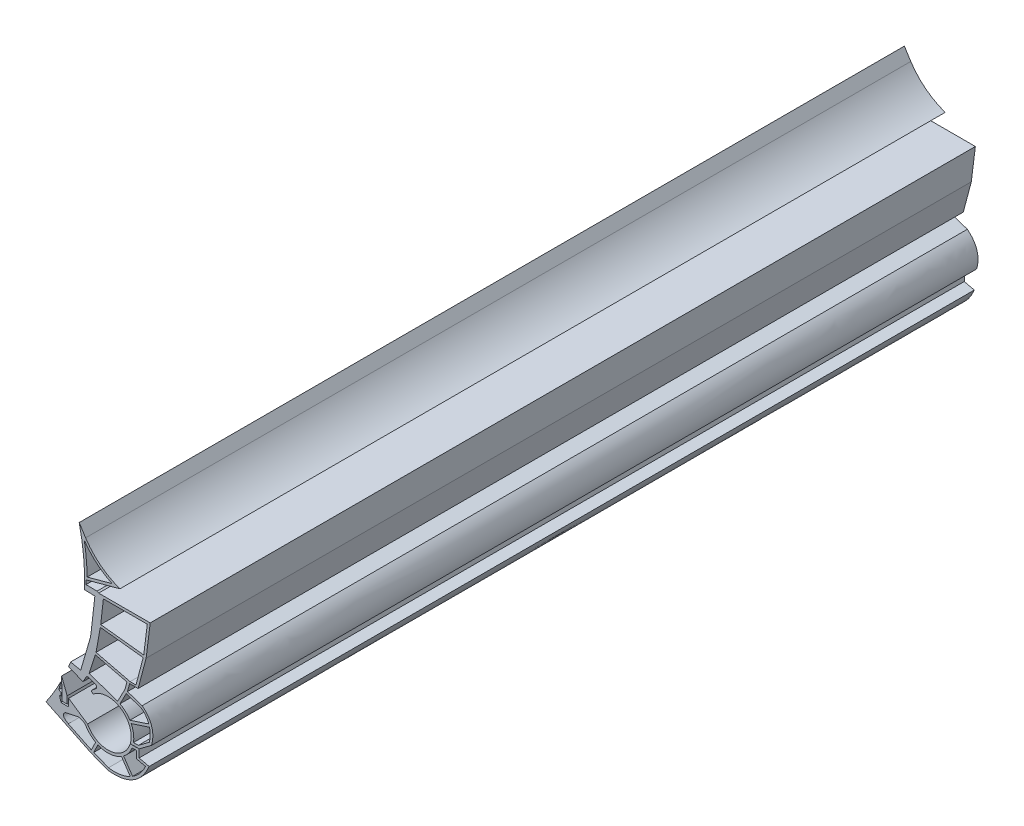
from build123d import *

# Parameters (mm, degrees)
BOSS_EXTRUDE1_DEPTH   = 800
BOSS_EXTRUDE1_2_DEPTH = 800
BOSS_EXTRUDE1_3_DEPTH = 800


with BuildPart() as part:
    # Sketch2 → Boss-Extrude1 (new body)
    with BuildSketch(Plane.XY):
        with BuildLine():
            Line((219.877743808, -7.333333333), (209.883300908, -7))
            ThreePointArc((209.883300908, -7), (209.036823939, 20.089953644), (204.708380722, 46.845265098))
            Line((204.708380722, 46.845265098), (210.908263166, 37.044972147))
            ThreePointArc((210.908263166, 37.044972147), (225.418988897, 21.257964998), (244.224799112, 10.95591384))
            Line((244.224799112, 10.95591384), (211.269993414, 2))
            Line((211.269993414, 2), (211.269993414, -2.012186433))
            Line((211.269993414, -2.012186433), (221.990475975, -2.114290898))
            Line((221.990475975, -2.114290898), (223.530977705, -3.027795155))
            Line((223.530977705, -3.027795155), (273.530977705, -3.027795155))
            Line((273.530977705, -3.027795155), (269.584815864, -34.639562765))
            Line((269.584815864, -34.639562765), (261.828573121, -63.977474169))
            Line((261.828573121, -63.977474169), (253.570603739, -63.920369552))
            Line((253.570603739, -63.920369552), (251.502867564, -71.746815931))
            Line((251.502867564, -71.746815931), (265.756145816, -76.42057877))
            add(Edge.make_bspline(
                [(265.756145816, -76.42057877), (279.732844517, -87.718519491), (274.80699177, -105.243303822)],
                knots=[0, 0, 0, 1, 1, 1], degree=2))
            Line((274.80699177, -105.243303822), (262.889701897, -114.073205773))
            Line((262.889701897, -114.073205773), (254.187014796, -114.073467609))
            ThreePointArc((254.187014796, -114.073467609), (245.005362752, -89.033401072), (218.370489992, -90.408617244))
            Line((218.370489992, -90.408617244), (216.987423166, -89.47817055))
            ThreePointArc((216.987423166, -89.47817055), (216.546928458, -88.6998252), (216.905234712, -87.880390212))
            Line((216.905234712, -87.880390212), (220.932114628, -84.522977972))
            ThreePointArc((220.932114628, -84.522977972), (221.623404057, -82.653573805), (220.356188922, -81.115159421))
            Line((220.356188922, -81.115159421), (213.922645584, -78.692485674))
            ThreePointArc((213.922645584, -78.692485674), (212.546582543, -78.680182493), (211.48830239, -79.559809676))
            Line((211.48830239, -79.559809676), (208.320966691, -85.013968481))
            Line((208.320966691, -85.013968481), (194.432902245, -79.346370583))
            ThreePointArc((194.432902245, -79.346370583), (195.418239612, -76.887655881), (196.372486568, -74.416708601))
            Line((196.372486568, -74.416708601), (206.163211734, -76.451825484))
            Line((206.163211734, -76.451825484), (215.396541258, -44.769744406))
            Line((215.396541258, -44.769744406), (216.201262108, -40.024272027))
            Line((216.201262108, -40.024272027), (219.877743808, -7.333333333))
        make_face()
        Polygon((270.699494071, -5.527795155), (267.255142009, -33.119683511), (225.555597681, -28.430077836), (228.131229539, -5.527795155), align=None, mode=Mode.SUBTRACT)
        Polygon((221.028914069, -54.008130098), (254.057209492, -62.078551489), (259.744710015, -62.078551489), (266.75063601, -35.578705754), (225.193651001, -30.905132557), align=None, mode=Mode.SUBTRACT)
        with BuildLine():
            Line((250.326268176, -73.991973356), (244.224799112, -85.63464351))
            ThreePointArc((244.224799112, -85.63464351), (249.640856314, -89.46696755), (253.858108107, -94.588995513))
            Line((253.858108107, -94.588995513), (272.107313629, -88.577563806))
            ThreePointArc((272.107313629, -88.577563806), (269.17492176, -82.962253968), (264.533682358, -78.650697003))
            Line((264.533682358, -78.650697003), (250.326268176, -73.991973356))
        make_face(mode=Mode.SUBTRACT)
        with BuildLine():
            Line((262.06445628, -111.573205773), (272.619054804, -103.75296551))
            ThreePointArc((272.619054804, -103.75296551), (273.555215096, -97.369625677), (272.889612093, -90.952430327))
            Line((272.889612093, -90.952430327), (255.088866515, -96.816322326))
            ThreePointArc((255.088866515, -96.816322326), (257.336724857, -104.023661365), (257.33049641, -111.573400722))
            Line((257.33049641, -111.573400722), (262.06445628, -111.573205773))
        make_face(mode=Mode.SUBTRACT)
        with BuildLine():
            Line((212.443278327, 4.909530906), (236.506394493, 11.449007942))
            ThreePointArc((236.506394493, 11.449007942), (221.606630296, 21.147833274), (209.704620684, 34.354360188))
            ThreePointArc((209.704620684, 34.354360188), (211.586770977, 19.679642969), (212.443278327, 4.909530906))
        make_face(mode=Mode.SUBTRACT)
        Polygon((249.157757395, -70.835874948), (241.952280674, -84.585184811), (214.328828436, -75.073832175), (220.269405707, -56.396096127), (250.989539733, -63.902521257), align=None, mode=Mode.SUBTRACT)
    extrude(amount=BOSS_EXTRUDE1_DEPTH)


with BuildPart() as body_2:
    # Sketch2 → Boss-Extrude1 2 (new body)
    with BuildSketch(Plane.XY):
        with BuildLine():
            Line((216.469459271, -141.037184205), (172.512257161, -119.747739558))
            ThreePointArc((172.512257161, -119.747739558), (180.123356683, -107.960994704), (186.930410904, -95.692327171))
            Line((186.930410904, -95.692327171), (184.936120706, -103.441553939))
            Line((184.936120706, -103.441553939), (187.292803793, -104.504288635))
            Line((187.292803793, -104.504288635), (187.292803793, -107.504288635))
            Line((187.292803793, -107.504288635), (185.612345377, -108.013264922))
            Line((185.612345377, -108.013264922), (187.166078479, -113.14313822))
            Line((187.166078479, -113.14313822), (194.485119153, -113.14313822))
            Line((194.485119153, -113.14313822), (194.485119153, -105.831804929))
            Line((194.485119153, -105.831804929), (212.772463132, -118.30531603))
            ThreePointArc((212.772463132, -118.30531603), (234.800277303, -130.138906076), (254.127625184, -114.273469605))
            Line((254.127625184, -114.273469605), (262.754736754, -114.273469605))
            Line((262.754736754, -114.273469605), (262.754736754, -121.826061943))
            Line((262.754736754, -121.826061943), (272.500467307, -124.066761831))
            add(Edge.make_bspline(
                [(272.500467307, -124.066761831), (261.187460089, -150.606305517), (232.597385362, -147.208325233)],
                knots=[0, 0, 0, 1, 1, 1], degree=2))
            Line((232.597385362, -147.208325233), (216.469459271, -141.037184205))
        make_face()
        with BuildLine():
            Line((256.441296727, -140.398444944), (247.744082063, -127.68467095))
            ThreePointArc((247.744082063, -127.68467095), (252.604105384, -122.799651864), (255.945892041, -116.77340095))
            Line((255.945892041, -116.77340095), (260.254736754, -116.773400241))
            Line((260.254736754, -116.773400241), (260.254736754, -123.81649767))
            Line((260.254736754, -123.81649767), (268.948965772, -125.815440477))
            ThreePointArc((268.948965772, -125.815440477), (263.803722581, -134.057768277), (256.441296727, -140.398444944))
        make_face(mode=Mode.SUBTRACT)
        with BuildLine():
            Line((218.734928689, -139.227271917), (233.197636825, -144.761238965))
            ThreePointArc((233.197636825, -144.761238965), (243.996021225, -144.989518192), (254.26668504, -141.647261193))
            Line((254.26668504, -141.647261193), (245.680415042, -129.095558837))
            ThreePointArc((245.680415042, -129.095558837), (234.457663773, -132.710529956), (222.826219463, -130.779813637))
            Line((222.826219463, -130.779813637), (218.734928689, -139.227271917))
        make_face(mode=Mode.SUBTRACT)
        with BuildLine():
            Line((194.115962412, -127.433113779), (216.468781859, -138.259078342))
            Line((216.468781859, -138.259078342), (220.611641642, -129.705139796))
            ThreePointArc((220.611641642, -129.705139796), (215.006853725, -125.519847458), (210.780992799, -119.945583472))
            add(Edge.make_bspline(
                [(203.512673415, -116.791372692), (207.758261172, -116.975234714), (210.780992799, -119.945583472)],
                knots=[0, 0, 0, 1, 1, 1], degree=2))
            add(Edge.make_bspline(
                [(203.512673415, -116.791372692), (197.698228021, -118.008638917), (191.883782627, -119.225905142)],
                knots=[0.316118576, 0.316118576, 0.316118576, 1, 1, 1], degree=2))
            add(Edge.make_bspline(
                [(191.883782627, -119.225905142), (185.65547594, -122.26514873), (194.115962412, -127.433113779)],
                knots=[0, 0, 0, 1, 1, 1], degree=2))
        make_face(mode=Mode.SUBTRACT)
    extrude(amount=BOSS_EXTRUDE1_2_DEPTH)


with BuildPart() as body_3:
    # Sketch2 → Boss-Extrude1 3 (new body)
    with BuildSketch(Plane.XY):
        Polygon((188.043162181, -111.504288635), (187.661207371, -90.503054317), (193.043162181, -104.504288635), (193.043162181, -111.504288635), align=None)
    extrude(amount=BOSS_EXTRUDE1_3_DEPTH)


solid = Compound([part.part, body_2.part, body_3.part])
